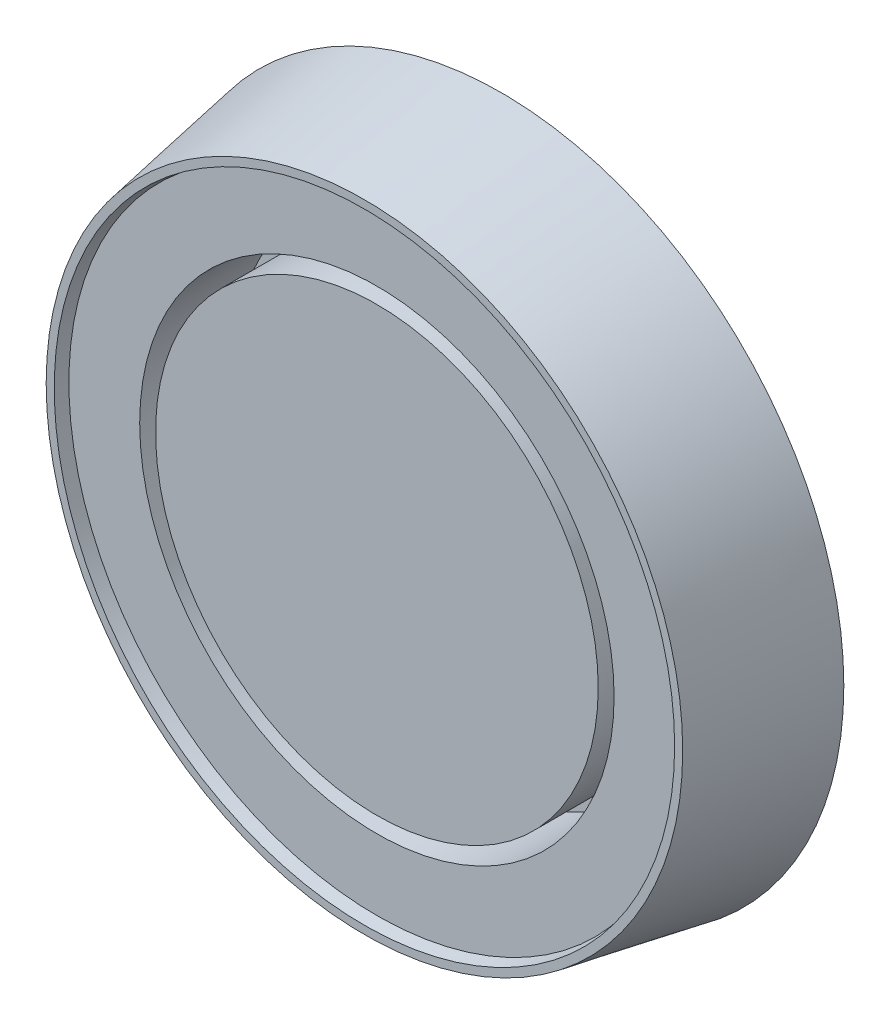
from build123d import *

# Parameters (mm, degrees)
SKETCH1_R           = 55
BOSS_EXTRUDE1_DEPTH = 20
BOSS_EXTRUDE1_TAPER = 10
SKETCH2_R           = 38.1
SKETCH2_R_2         = 35.55
CUT_EXTRUDE1_DEPTH  = 15
SKETCH3_R           = 51.473460386
SKETCH3_R_2         = 49.473460386
BOSS_EXTRUDE2_DEPTH = 2
BOSS_EXTRUDE2_TAPER = 10


with BuildPart() as part:
    # Sketch1 → Boss-Extrude1 (new body)
    with BuildSketch(Plane.XY):
        Circle(SKETCH1_R)
    extrude(amount=BOSS_EXTRUDE1_DEPTH, taper=BOSS_EXTRUDE1_TAPER)

    # Sketch2 → Cut-Extrude1 (cut)
    with BuildSketch(Plane.XY.offset(20)):
        Circle(SKETCH2_R)
        Circle(SKETCH2_R_2, mode=Mode.SUBTRACT)
    extrude(amount=-CUT_EXTRUDE1_DEPTH, mode=Mode.SUBTRACT)

    # Sketch3 → Boss-Extrude2 (add)
    with BuildSketch(Plane.XY.offset(20)):
        Circle(SKETCH3_R)
        Circle(SKETCH3_R_2, mode=Mode.SUBTRACT)
    extrude(amount=BOSS_EXTRUDE2_DEPTH, taper=BOSS_EXTRUDE2_TAPER)


solid = part.part
